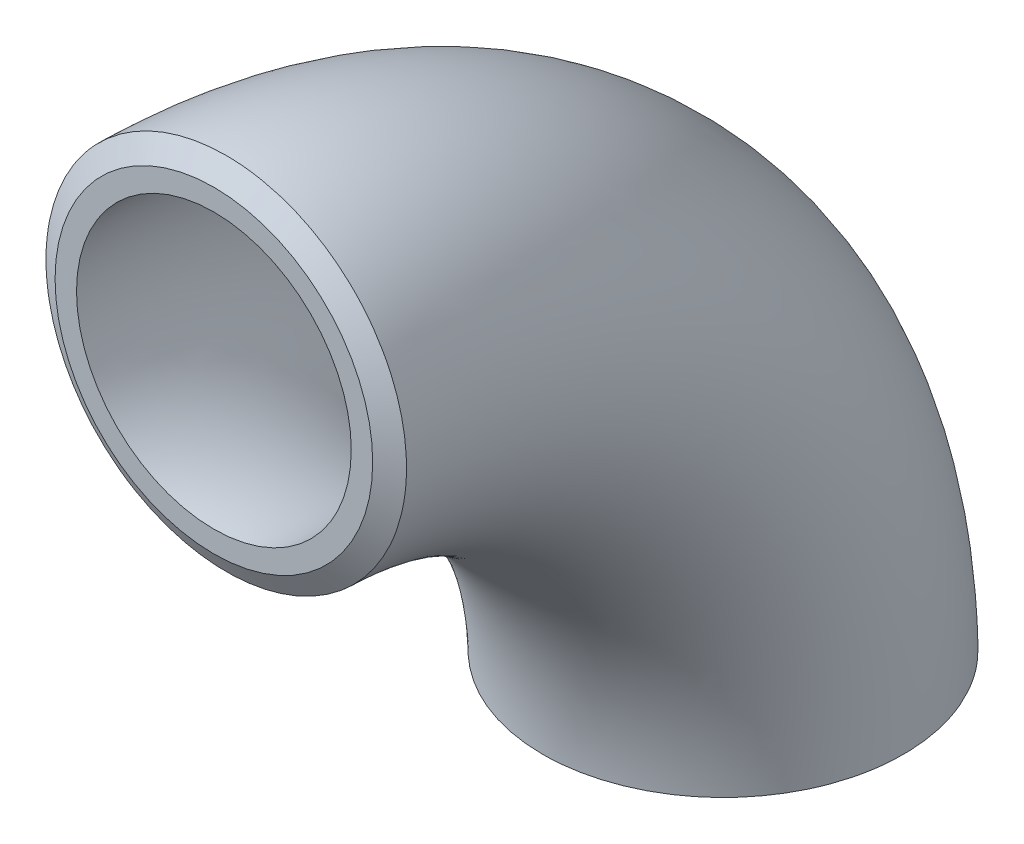
from build123d import *

# Parameters (mm, degrees)
ROHR_R   = 13.45
ROHR_R_2 = 10.25


with BuildPart() as part:
    # Bogen: sweep along a path in Pfad
    with BuildLine(Plane(origin=(0, 0, 0), x_dir=(0, 0, -1), z_dir=(1, 0, 0))) as bogen_path:
        ThreePointArc((0, -38), (-11.129942315, -11.129942315), (-38, 0))
    # Rohr → Bogen (sweep)
    with BuildSketch(Plane(origin=(0, -38, 0), x_dir=(-1, 0, 0), z_dir=(0, -1, 0))):
        Circle(ROHR_R)
        Circle(ROHR_R_2, mode=Mode.SUBTRACT)
    sweep(path=bogen_path.line)

    # SkzFase one side → Fase1 (revolve, cut)
    with BuildSketch(Plane(origin=(0, 0, 0), x_dir=(0, 0, -1), z_dir=(1, 0, 0)), mode=Mode.PRIVATE) as fase1_sk:
        Polygon((15.45, -35.921539031), (11.85, -38), (15.45, -38), align=None)
    revolve(fase1_sk.sketch.rotate(Axis((0, 0, 0), (0, -1, 0)), 180), axis=Axis((0, 0, 0), (0, -1, 0)), mode=Mode.SUBTRACT)  # turned: the seam where the file's is

    # Skizze1_3 → Fase2 (revolve, cut)
    with BuildSketch(Plane(origin=(0, 0, 0), x_dir=(0, 0, -1), z_dir=(1, 0, 0))):
        Polygon((-35.921539031, 15.45), (-38, 11.85), (-38, 15.45), align=None)
    revolve(axis=Axis((0, 0, 0), (0, 0, 1)), mode=Mode.SUBTRACT)


solid = part.part
